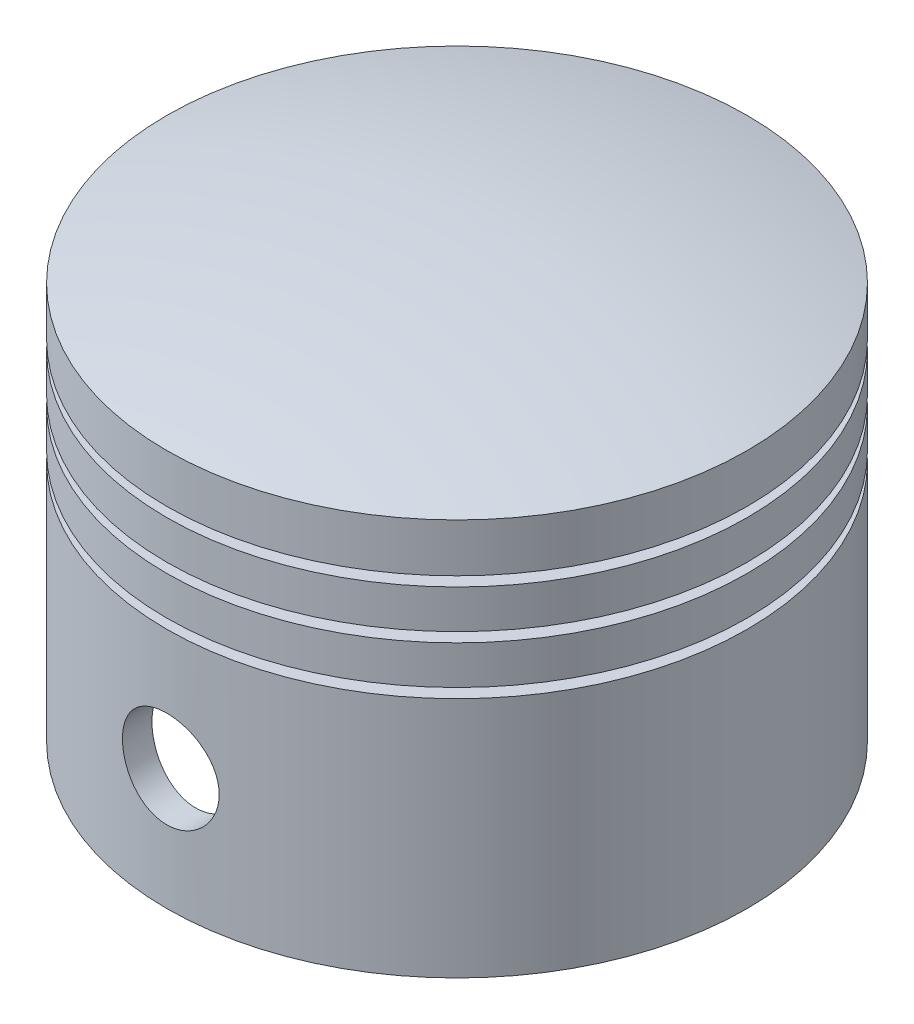
from build123d import *

# Parameters (mm, degrees)
SKETCH1_R                           = 30
BOSS_EXTRUDE1_DEPTH                 = 45
SKETCH2_W                           = 4
SKETCH2_H                           = 1
SKETCH3_R                           = 5
CUT_EXTRUDE1_DEPTH                  = 62.846584384
CUT_EXTRUDE1_DEPTH_BACK             = 62.846584384
CUT_EXTRUDE3_REACH                  = 63.847
CUT_EXTRUDE3_END_RADIUS             = 27
SKETCH8_W                           = 35
SKETCH8_H                           = 70
CUT_EXTRUDE3_DIRECTION_2_REACH      = 63.847
CUT_EXTRUDE3_DIRECTION_2_END_RADIUS = 27
SKETCH9_W                           = 15
SKETCH9_H                           = 35
SKETCH9_H_2                         = 2
CHAMFER2_SIZE                       = 5


with BuildPart() as part:
    # Sketch1 → Boss-Extrude1 (new body)
    with BuildSketch(Plane(origin=(0, 0, 0), x_dir=(1, 0, 0), z_dir=(0, 1, 0))):
        with Locations(Location((0, 0, 0), (0, 0, 90))):
            Circle(SKETCH1_R)
    extrude(amount=BOSS_EXTRUDE1_DEPTH)

    # Sketch2 → Cut-Revolve3 (revolve, cut)
    with BuildSketch(Plane.XY, mode=Mode.PRIVATE) as cut_revolve3_sk:
        with Locations((30, 25.5)):
            Rectangle(SKETCH2_W, SKETCH2_H)
        with Locations((30, 30.5)):
            Rectangle(SKETCH2_W, SKETCH2_H)
        with Locations((30, 35.5)):
            Rectangle(SKETCH2_W, SKETCH2_H)
        with BuildLine():
            Line((0, 45), (0, 47.512456789))
            Line((0, 47.512456789), (33.213865232, 47.512456789))
            Line((33.213865232, 47.512456789), (30, 41))
            ThreePointArc((30, 41), (15.13274595, 43.995594628), (0, 45))
        make_face()
    revolve(cut_revolve3_sk.sketch.rotate(Axis((0, 0, 0), (0, 1, 0)), 90), axis=Axis((0, 0, 0), (0, 1, 0)), mode=Mode.SUBTRACT)

    # Sketch3 → Cut-Extrude1 (cut, two sides)
    with BuildSketch(Plane.XY) as cut_extrude1_sk:
        with Locations((0, 12.5)):
            Circle(SKETCH3_R)
    extrude(amount=CUT_EXTRUDE1_DEPTH, mode=Mode.SUBTRACT)
    extrude(cut_extrude1_sk.sketch, amount=-CUT_EXTRUDE1_DEPTH_BACK, mode=Mode.SUBTRACT)

    # Cut-Extrude3: up to this cylinder (the profile starts inside it)
    cut_extrude3_end = Plane(origin=(0, 0, 0), z_dir=(0, -1, 0)) * Cylinder(CUT_EXTRUDE3_END_RADIUS, 182.694, mode=Mode.PRIVATE)
    # Sketch8 → Cut-Extrude3 (cut, up to the surface)
    with BuildSketch(Plane.XY, mode=Mode.PRIVATE) as cut_extrude3_sk1:
        Rectangle(SKETCH8_W, SKETCH8_H)
    cut_extrude3_tool1 = extrude(cut_extrude3_sk1.sketch, amount=-CUT_EXTRUDE3_REACH, mode=Mode.PRIVATE) & cut_extrude3_end
    add(cut_extrude3_tool1.solids().sort_by_distance((0, 0, 0))[0], mode=Mode.SUBTRACT)

    # Cut-Extrude3 direction 2: up to this cylinder (the profile starts inside it)
    cut_extrude3_direction_2_end = Plane(origin=(0, 0, 0), z_dir=(0, -1, 0)) * Cylinder(CUT_EXTRUDE3_DIRECTION_2_END_RADIUS, 182.694, mode=Mode.PRIVATE)
    # Sketch8 → Cut-Extrude3 direction 2 (cut, up to the surface)
    with BuildSketch(Plane.XY, mode=Mode.PRIVATE) as cut_extrude3_direction_2_sk1:
        Rectangle(SKETCH8_W, SKETCH8_H)
    cut_extrude3_direction_2_tool1 = extrude(cut_extrude3_direction_2_sk1.sketch, amount=CUT_EXTRUDE3_DIRECTION_2_REACH, mode=Mode.PRIVATE) & cut_extrude3_direction_2_end
    add(cut_extrude3_direction_2_tool1.solids().sort_by_distance((0, 0, 0))[0], mode=Mode.SUBTRACT)

    # Sketch9 → Cut-Revolve4 (revolve, cut)
    with BuildSketch(Plane.XY):
        with Locations((-7.5, 17.5)):
            Rectangle(SKETCH9_W, SKETCH9_H)
        with Locations((-7.5, 36)):
            Rectangle(SKETCH9_W, SKETCH9_H_2)
        Polygon((-27, 35), (-15, 35), (-15, 37), (0, 37), (0, 39), (-27, 39), align=None)
        with BuildLine():
            ThreePointArc((0, 42), (-13.583077707, 41.247699365), (-27, 39))
            Line((-27, 39), (0, 39))
            Line((0, 39), (0, 42))
        make_face()
        with BuildLine():
            Line((0, 39), (27, 39))
            ThreePointArc((27, 39), (13.583077707, 41.247699365), (0, 42))
            Line((0, 42), (0, 39))
        make_face()
    revolve(axis=Axis((0, 0, 0), (0, -1, 0)), mode=Mode.SUBTRACT)

    # Chamfer2
    chamfer2_edges = [part.edges().sort_by_distance(p)[0] for p in [
        (17.5, 0, 0),
        (-17.5, 0, 0),
    ]]
    chamfer(chamfer2_edges, length=CHAMFER2_SIZE)


solid = part.part
